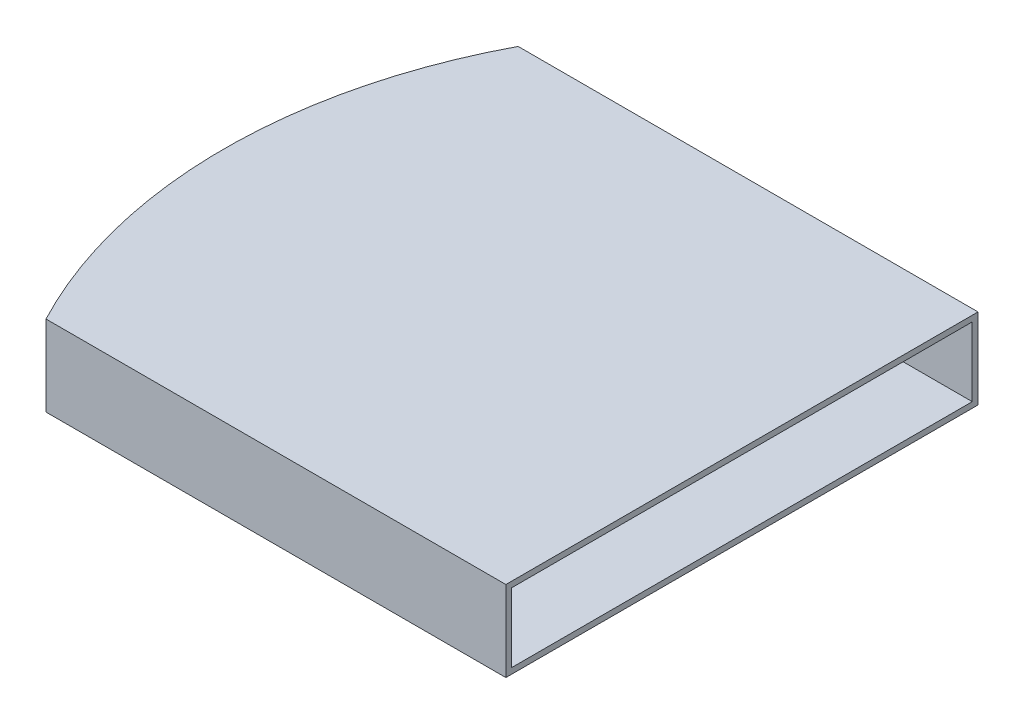
from build123d import *

# Parameters (mm, degrees)
BOSS_EXTRUDE1_DEPTH = 44.45
CUT_EXTRUDE2_DEPTH  = 254


with BuildPart() as part:
    # Sketch1 → Boss-Extrude1 (new body)
    with BuildSketch(Plane(origin=(0, 0, 0), x_dir=(1, 0, 0), z_dir=(0, 1, 0))):
        with BuildLine():
            Line((-253.572226701, 260.35), (0, 260.35))
            Line((0, 260.35), (0, 0))
            Line((0, 0), (-253.572226701, 0))
            ThreePointArc((-253.572226701, 0), (-285.75, 130.175), (-253.572226701, 260.35))
        make_face()
    extrude(amount=BOSS_EXTRUDE1_DEPTH)

    # Sketch2 → Cut-Extrude2 (cut)
    with BuildSketch(Plane.XY.offset(-3.175)):
        Polygon((-247.222226701, 41.275), (-215.252530753, 3.175), (32.837570188, 3.175), (32.837570188, 41.275), align=None)
    extrude(amount=-CUT_EXTRUDE2_DEPTH, mode=Mode.SUBTRACT)


solid = part.part
